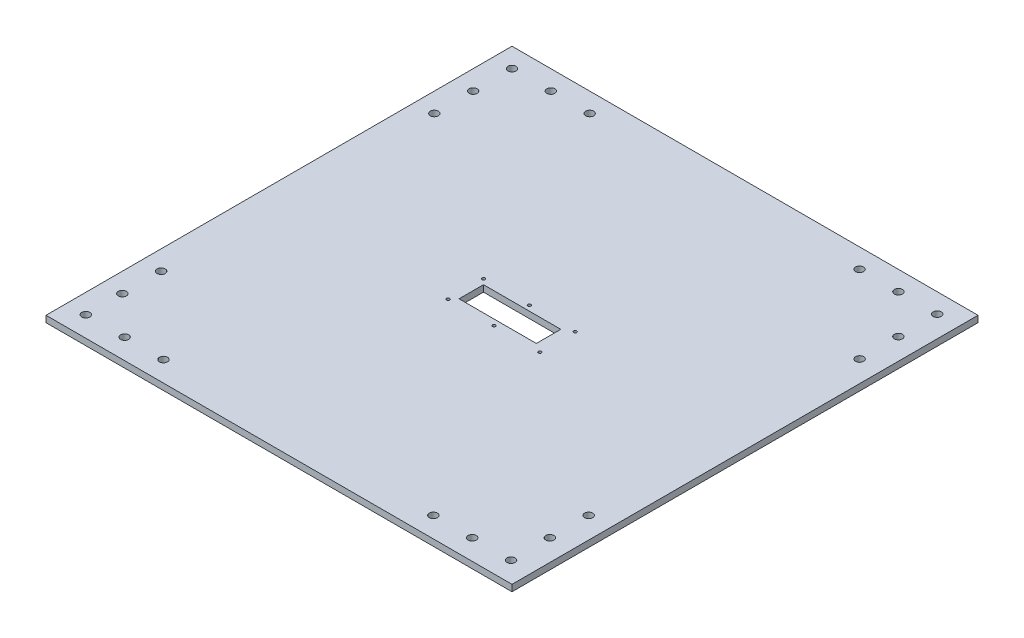
from build123d import *

# Parameters (mm, degrees)
SKETCH2_W           = 457.2
SKETCH2_H           = 457.2
SKETCH2_R           = 1.499997
SKETCH2_R_2         = 3.96875
SKETCH2_W_2         = 75.854546825
SKETCH2_H_2         = 24.0000028
BOSS_EXTRUDE1_DEPTH = 6.35


with BuildPart() as part:
    # Sketch2 → Boss-Extrude1 (new body)
    with BuildSketch(Plane(origin=(0, 0, 0), x_dir=(1, 0, 0), z_dir=(0, 1, 0))):
        with Locations((109.717331557, 168.168299308)):
            Rectangle(SKETCH2_W, SKETCH2_H)
        with Locations((154.700731557, 185.216049573)):
            Circle(SKETCH2_R, mode=Mode.SUBTRACT)
        with Locations((154.700731557, 150.518638726)):
            Circle(SKETCH2_R, mode=Mode.SUBTRACT)
        with Locations((64.733931557, 150.518638726)):
            Circle(SKETCH2_R, mode=Mode.SUBTRACT)
        with Locations((64.733931557, 185.216049573)):
            Circle(SKETCH2_R, mode=Mode.SUBTRACT)
        with Locations((-99.832668443, 377.718299308)):
            Circle(SKETCH2_R_2, mode=Mode.SUBTRACT)
        with Locations((317.367309957, 377.718299308)):
            Circle(SKETCH2_R_2, mode=Mode.SUBTRACT)
        with Locations((-99.832668443, -40.431689892)):
            Circle(SKETCH2_R_2, mode=Mode.SUBTRACT)
        with Locations((317.367309957, -40.431689892)):
            Circle(SKETCH2_R_2, mode=Mode.SUBTRACT)
        with Locations((109.717331557, 185.216049573)):
            Circle(SKETCH2_R, mode=Mode.SUBTRACT)
        with Locations((109.717331557, 150.518638726)):
            Circle(SKETCH2_R, mode=Mode.SUBTRACT)
        with Locations((-61.732668443, 377.718299308)):
            Circle(SKETCH2_R_2, mode=Mode.SUBTRACT)
        with Locations((-23.632668443, 377.718299308)):
            Circle(SKETCH2_R_2, mode=Mode.SUBTRACT)
        with Locations((-99.832668443, 339.618299308)):
            Circle(SKETCH2_R_2, mode=Mode.SUBTRACT)
        with Locations((-99.832668443, 301.518299308)):
            Circle(SKETCH2_R_2, mode=Mode.SUBTRACT)
        with Locations((241.167309957, 377.718299308)):
            Circle(SKETCH2_R_2, mode=Mode.SUBTRACT)
        with Locations((279.267309957, 377.718299308)):
            Circle(SKETCH2_R_2, mode=Mode.SUBTRACT)
        with Locations((317.367309957, 339.618299308)):
            Circle(SKETCH2_R_2, mode=Mode.SUBTRACT)
        with Locations((317.367309957, 301.518299308)):
            Circle(SKETCH2_R_2, mode=Mode.SUBTRACT)
        with Locations((317.367309957, -2.331689892)):
            Circle(SKETCH2_R_2, mode=Mode.SUBTRACT)
        with Locations((317.367309957, 35.768310108)):
            Circle(SKETCH2_R_2, mode=Mode.SUBTRACT)
        with Locations((279.267309957, -40.431689892)):
            Circle(SKETCH2_R_2, mode=Mode.SUBTRACT)
        with Locations((241.167309957, -40.431689892)):
            Circle(SKETCH2_R_2, mode=Mode.SUBTRACT)
        with Locations((-61.732668443, -40.431689892)):
            Circle(SKETCH2_R_2, mode=Mode.SUBTRACT)
        with Locations((-23.632668443, -40.431689892)):
            Circle(SKETCH2_R_2, mode=Mode.SUBTRACT)
        with Locations((-99.832668443, -4.616265021)):
            Circle(SKETCH2_R_2, mode=Mode.SUBTRACT)
        with Locations((-99.832668443, 33.483734979)):
            Circle(SKETCH2_R_2, mode=Mode.SUBTRACT)
        with Locations((107.67770497, 168.168299308)):
            Rectangle(SKETCH2_W_2, SKETCH2_H_2, mode=Mode.SUBTRACT)
    extrude(amount=BOSS_EXTRUDE1_DEPTH)


solid = part.part
